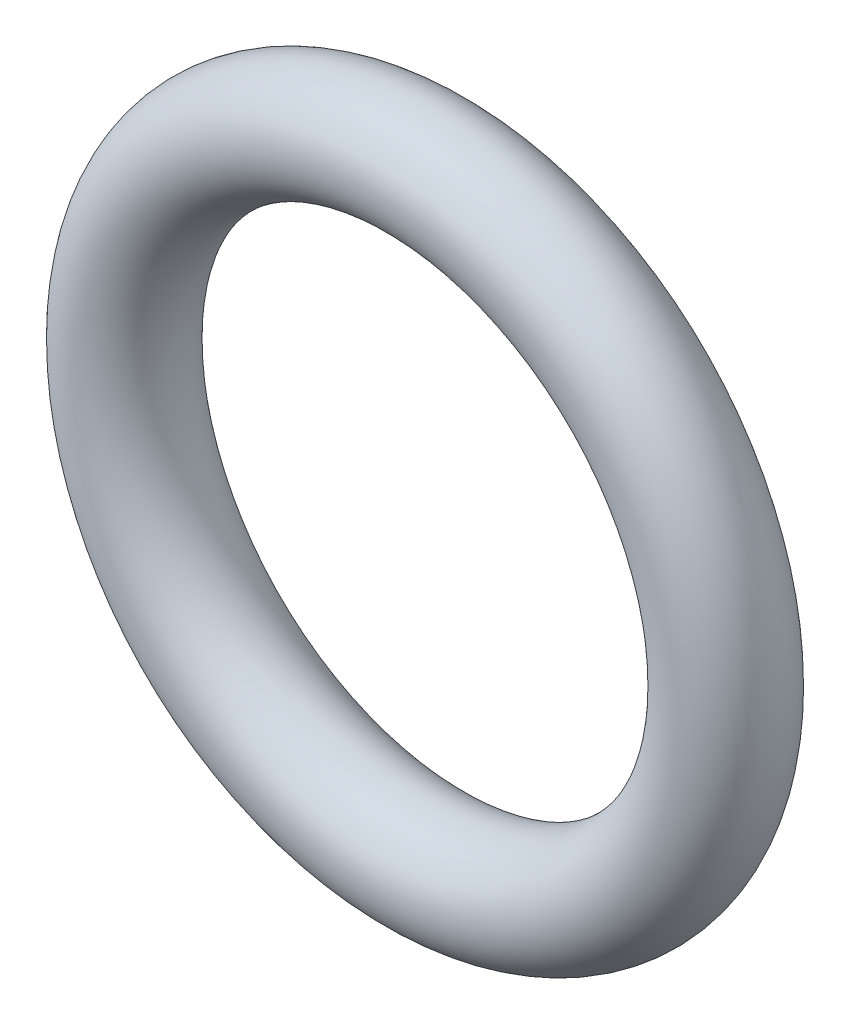
from build123d import *

# Parameters (mm, degrees)
SKETCH2_R = 0.889


with BuildPart() as part:
    # Base-Sweep: sweep along a path in Sketch1
    with BuildLine(Plane.XY) as base_sweep_path:
        CenterArc((0, 0), 4.85775, 0, 360)
    # Sketch2 → Base-Sweep (sweep)
    with BuildSketch(Plane(origin=(0, 0, 0), x_dir=(1, 0, 0), z_dir=(0, 1, 0))):
        with Locations((4.85775, 0)):
            Circle(SKETCH2_R)
    sweep(path=base_sweep_path.line)


solid = part.part
